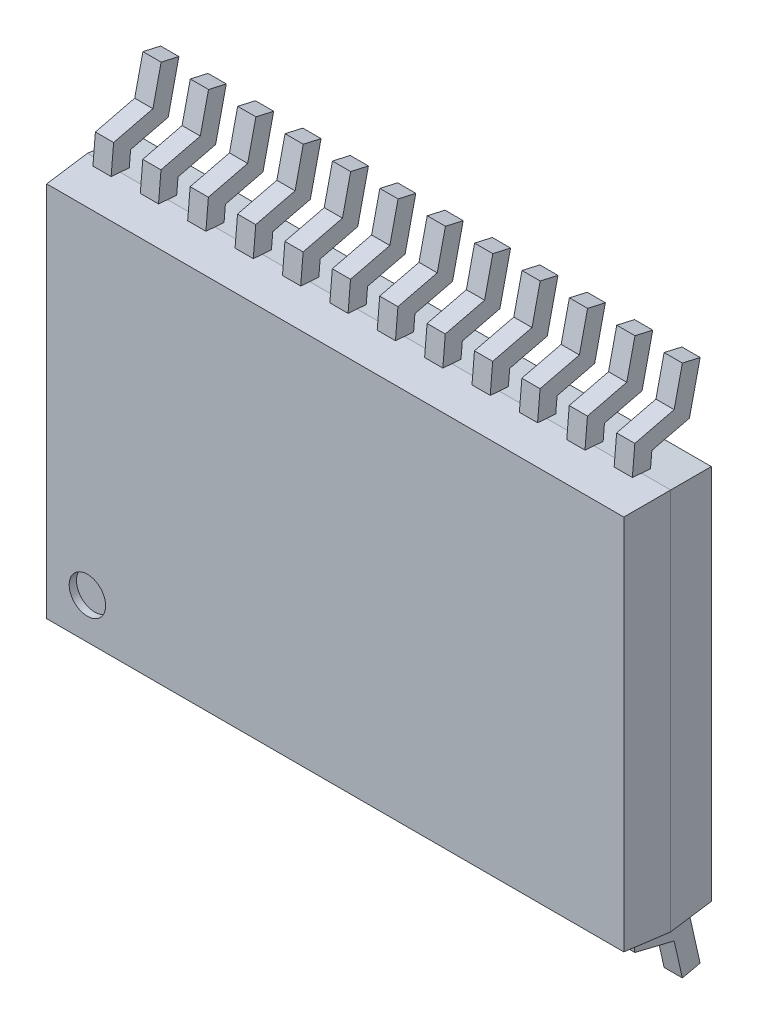
from build123d import *

# Parameters (mm, degrees)
SKETCH1_W             = 8
SKETCH1_H             = 5.25
BOSS_EXTRUDE1_DEPTH   = 0.6
BOSS_EXTRUDE1_TAPER   = 4
EXTRUDE_THIN1_DEPTH   = 0.125
LPATTERN1_COUNT       = 12
LPATTERN1_PITCH       = 0.65
CUT_EXTRUDE2_START    = 0.5
SKETCH6_R             = 0.25
CUT_EXTRUDE2_DEPTH    = 0.2
MIRROR2_COPY_1_DEPTH  = 0.125
MIRROR2_COPY_2_DEPTH  = 0.125
MIRROR2_COPY_3_DEPTH  = 0.125
MIRROR2_COPY_4_DEPTH  = 0.125
MIRROR2_COPY_5_DEPTH  = 0.125
MIRROR2_COPY_6_DEPTH  = 0.125
MIRROR2_COPY_7_DEPTH  = 0.125
MIRROR2_COPY_8_DEPTH  = 0.125
MIRROR2_COPY_9_DEPTH  = 0.125
MIRROR2_COPY_10_DEPTH = 0.125
MIRROR2_COPY_11_DEPTH = 0.125


with BuildPart() as part:
    # Sketch1 → Boss-Extrude1 (new body)
    with BuildSketch(Plane.XY):
        with Locations((4, 2.625)):
            Rectangle(SKETCH1_W, SKETCH1_H)
    boss_extrude1 = extrude(amount=BOSS_EXTRUDE1_DEPTH, taper=BOSS_EXTRUDE1_TAPER)

    # Mirror1: Boss-Extrude1 across plane
    add(boss_extrude1.mirror(Plane.XY))

    # Sketch5 → Extrude-Thin1 (add, symmetric)
    with BuildSketch(Plane(origin=(0.325, 0, 0), x_dir=(0, 0, -1), z_dir=(1, 0, 0))):
        Polygon((-0.124523185, -0.010907632), (-0.090524561, -0.399041073), (0.448693138, -0.530649047), (0.561242348, -1.027610141), (0.805067532, -0.972389859), (0.658331595, -0.324477253), (0.142881197, -0.198670214), (0.124523185, 0.010907632), align=None)
    extrude_thin1 = extrude(amount=EXTRUDE_THIN1_DEPTH, both=True)

    # LPattern1: Extrude-Thin1 ×12
    with Locations(*[(i * LPATTERN1_PITCH, 0, 0) for i in range(1, LPATTERN1_COUNT)]):
        add(extrude_thin1)

    # Sketch6 → Cut-Extrude2 (cut)
    with BuildSketch(Plane.XY.offset(CUT_EXTRUDE2_START)):
        with Locations((0.6, 0.6)):
            Circle(SKETCH6_R)
    extrude(amount=CUT_EXTRUDE2_DEPTH, mode=Mode.SUBTRACT)

    # Mirror2: Extrude-Thin1 across plane
    add(extrude_thin1.mirror(Plane.ZX.offset(2.625)))

    # Mirror2 copy 1 sketch → Mirror2 copy 1 (add, symmetric)
    with BuildSketch(Plane(origin=(0.975, 5.25, 0), x_dir=(0, 0, -1), z_dir=(1, 0, 0))):
        Polygon((-0.124523185, 0.010907632), (-0.090524561, 0.399041073), (0.448693138, 0.530649047), (0.561242348, 1.027610141), (0.805067532, 0.972389859), (0.658331595, 0.324477253), (0.142881197, 0.198670214), (0.124523185, -0.010907632), align=None)
    extrude(amount=MIRROR2_COPY_1_DEPTH, both=True)

    # Mirror2 copy 2 sketch → Mirror2 copy 2 (add, symmetric)
    with BuildSketch(Plane(origin=(1.625, 5.25, 0), x_dir=(0, 0, -1), z_dir=(1, 0, 0))):
        Polygon((-0.124523185, 0.010907632), (-0.090524561, 0.399041073), (0.448693138, 0.530649047), (0.561242348, 1.027610141), (0.805067532, 0.972389859), (0.658331595, 0.324477253), (0.142881197, 0.198670214), (0.124523185, -0.010907632), align=None)
    extrude(amount=MIRROR2_COPY_2_DEPTH, both=True)

    # Mirror2 copy 3 sketch → Mirror2 copy 3 (add, symmetric)
    with BuildSketch(Plane(origin=(2.275, 5.25, 0), x_dir=(0, 0, -1), z_dir=(1, 0, 0))):
        Polygon((-0.124523185, 0.010907632), (-0.090524561, 0.399041073), (0.448693138, 0.530649047), (0.561242348, 1.027610141), (0.805067532, 0.972389859), (0.658331595, 0.324477253), (0.142881197, 0.198670214), (0.124523185, -0.010907632), align=None)
    extrude(amount=MIRROR2_COPY_3_DEPTH, both=True)

    # Mirror2 copy 4 sketch → Mirror2 copy 4 (add, symmetric)
    with BuildSketch(Plane(origin=(2.925, 5.25, 0), x_dir=(0, 0, -1), z_dir=(1, 0, 0))):
        Polygon((-0.124523185, 0.010907632), (-0.090524561, 0.399041073), (0.448693138, 0.530649047), (0.561242348, 1.027610141), (0.805067532, 0.972389859), (0.658331595, 0.324477253), (0.142881197, 0.198670214), (0.124523185, -0.010907632), align=None)
    extrude(amount=MIRROR2_COPY_4_DEPTH, both=True)

    # Mirror2 copy 5 sketch → Mirror2 copy 5 (add, symmetric)
    with BuildSketch(Plane(origin=(3.575, 5.25, 0), x_dir=(0, 0, -1), z_dir=(1, 0, 0))):
        Polygon((-0.124523185, 0.010907632), (-0.090524561, 0.399041073), (0.448693138, 0.530649047), (0.561242348, 1.027610141), (0.805067532, 0.972389859), (0.658331595, 0.324477253), (0.142881197, 0.198670214), (0.124523185, -0.010907632), align=None)
    extrude(amount=MIRROR2_COPY_5_DEPTH, both=True)

    # Mirror2 copy 6 sketch → Mirror2 copy 6 (add, symmetric)
    with BuildSketch(Plane(origin=(4.225, 5.25, 0), x_dir=(0, 0, -1), z_dir=(1, 0, 0))):
        Polygon((-0.124523185, 0.010907632), (-0.090524561, 0.399041073), (0.448693138, 0.530649047), (0.561242348, 1.027610141), (0.805067532, 0.972389859), (0.658331595, 0.324477253), (0.142881197, 0.198670214), (0.124523185, -0.010907632), align=None)
    extrude(amount=MIRROR2_COPY_6_DEPTH, both=True)

    # Mirror2 copy 7 sketch → Mirror2 copy 7 (add, symmetric)
    with BuildSketch(Plane(origin=(4.875, 5.25, 0), x_dir=(0, 0, -1), z_dir=(1, 0, 0))):
        Polygon((-0.124523185, 0.010907632), (-0.090524561, 0.399041073), (0.448693138, 0.530649047), (0.561242348, 1.027610141), (0.805067532, 0.972389859), (0.658331595, 0.324477253), (0.142881197, 0.198670214), (0.124523185, -0.010907632), align=None)
    extrude(amount=MIRROR2_COPY_7_DEPTH, both=True)

    # Mirror2 copy 8 sketch → Mirror2 copy 8 (add, symmetric)
    with BuildSketch(Plane(origin=(5.525, 5.25, 0), x_dir=(0, 0, -1), z_dir=(1, 0, 0))):
        Polygon((-0.124523185, 0.010907632), (-0.090524561, 0.399041073), (0.448693138, 0.530649047), (0.561242348, 1.027610141), (0.805067532, 0.972389859), (0.658331595, 0.324477253), (0.142881197, 0.198670214), (0.124523185, -0.010907632), align=None)
    extrude(amount=MIRROR2_COPY_8_DEPTH, both=True)

    # Mirror2 copy 9 sketch → Mirror2 copy 9 (add, symmetric)
    with BuildSketch(Plane(origin=(6.175, 5.25, 0), x_dir=(0, 0, -1), z_dir=(1, 0, 0))):
        Polygon((-0.124523185, 0.010907632), (-0.090524561, 0.399041073), (0.448693138, 0.530649047), (0.561242348, 1.027610141), (0.805067532, 0.972389859), (0.658331595, 0.324477253), (0.142881197, 0.198670214), (0.124523185, -0.010907632), align=None)
    extrude(amount=MIRROR2_COPY_9_DEPTH, both=True)

    # Mirror2 copy 10 sketch → Mirror2 copy 10 (add, symmetric)
    with BuildSketch(Plane(origin=(6.825, 5.25, 0), x_dir=(0, 0, -1), z_dir=(1, 0, 0))):
        Polygon((-0.124523185, 0.010907632), (-0.090524561, 0.399041073), (0.448693138, 0.530649047), (0.561242348, 1.027610141), (0.805067532, 0.972389859), (0.658331595, 0.324477253), (0.142881197, 0.198670214), (0.124523185, -0.010907632), align=None)
    extrude(amount=MIRROR2_COPY_10_DEPTH, both=True)

    # Mirror2 copy 11 sketch → Mirror2 copy 11 (add, symmetric)
    with BuildSketch(Plane(origin=(7.475, 5.25, 0), x_dir=(0, 0, -1), z_dir=(1, 0, 0))):
        Polygon((-0.124523185, 0.010907632), (-0.090524561, 0.399041073), (0.448693138, 0.530649047), (0.561242348, 1.027610141), (0.805067532, 0.972389859), (0.658331595, 0.324477253), (0.142881197, 0.198670214), (0.124523185, -0.010907632), align=None)
    extrude(amount=MIRROR2_COPY_11_DEPTH, both=True)


solid = part.part
